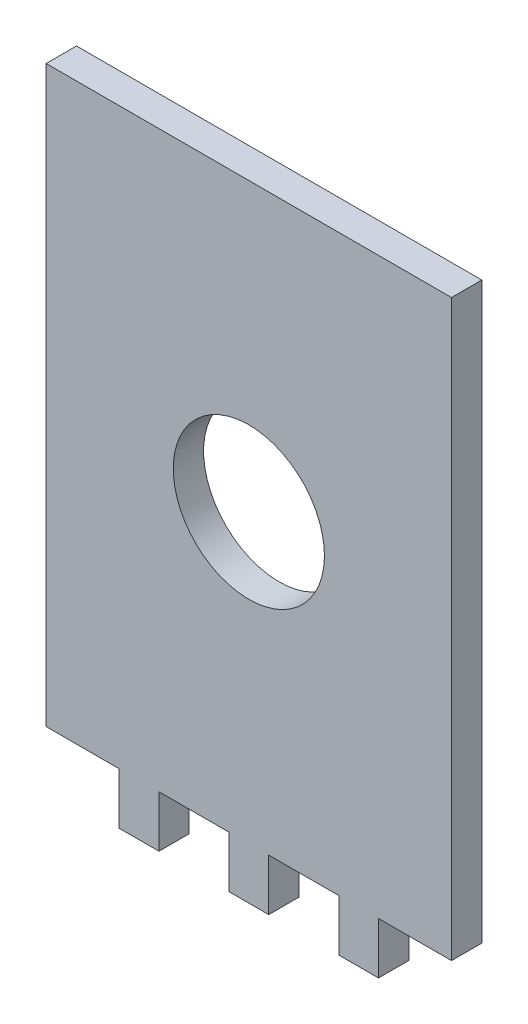
from build123d import *

# Parameters (mm, degrees)
SKETCH1_W           = 42.3
SKETCH1_H           = 60
SKETCH1_R           = 8
SKETCH1_W_2         = 4
SKETCH1_H_2         = 5.4
BOSS_EXTRUDE1_DEPTH = 3.175
SKETCH2_R           = 7.95936
BOSS_EXTRUDE3_DEPTH = 3.175
SKETCH3_R           = 7.91872
BOSS_EXTRUDE4_DEPTH = 3.175


with BuildPart() as part:
    # Sketch1 → Boss-Extrude1 (new body)
    with BuildSketch(Plane.XY):
        Rectangle(SKETCH1_W, SKETCH1_H)
        Circle(SKETCH1_R, mode=Mode.SUBTRACT)
        with Locations((0, -32.7)):
            Rectangle(SKETCH1_W_2, SKETCH1_H_2)
        with Locations((-11.5, -32.7)):
            Rectangle(SKETCH1_W_2, SKETCH1_H_2)
        with Locations((11.5, -32.7)):
            Rectangle(SKETCH1_W_2, SKETCH1_H_2)
    extrude(amount=BOSS_EXTRUDE1_DEPTH)

    # Sketch2 → Boss-Extrude3 (add)
    with BuildSketch(Plane.XY.offset(3.175)):
        Polygon((21.19064, -30.04064), (21.19064, 30.04064), (-21.19064, 30.04064), (-21.19064, -30.04064), (-13.54064, -30.04064), (-13.54064, -35.44064), (-9.45936, -35.44064), (-9.45936, -30.04064), (-2.04064, -30.04064), (-2.04064, -35.44064), (2.04064, -35.44064), (2.04064, -30.04064), (9.45936, -30.04064), (9.45936, -35.44064), (13.54064, -35.44064), (13.54064, -30.04064), align=None)
        Circle(SKETCH2_R, mode=Mode.SUBTRACT)
    extrude(amount=-BOSS_EXTRUDE3_DEPTH)

    # Sketch3 → Boss-Extrude4 (add)
    with BuildSketch(Plane.XY.offset(3.175)):
        Polygon((-21.23128, 30.08128), (-21.23128, -30.08128), (-13.58128, -30.08128), (-13.58128, -35.48128), (-9.41872, -35.48128), (-9.41872, -30.08128), (-2.08128, -30.08128), (-2.08128, -35.48128), (2.08128, -35.48128), (2.08128, -30.08128), (9.41872, -30.08128), (9.41872, -35.48128), (13.58128, -35.48128), (13.58128, -30.08128), (21.23128, -30.08128), (21.23128, 30.08128), align=None)
        Circle(SKETCH3_R, mode=Mode.SUBTRACT)
    extrude(amount=-BOSS_EXTRUDE4_DEPTH)


solid = part.part
